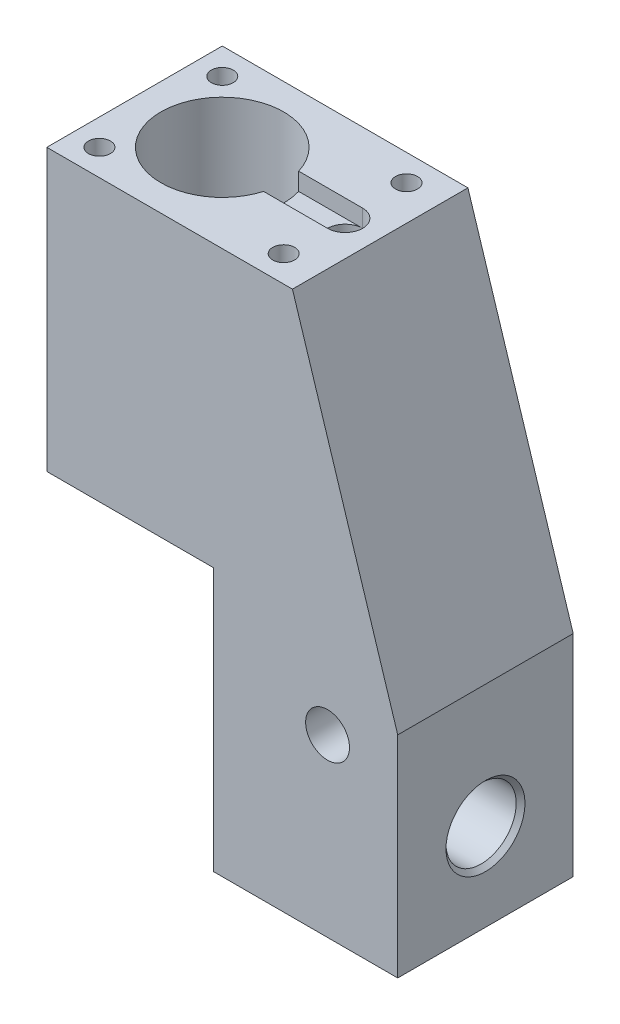
from build123d import *

# Parameters (mm, degrees)
SKETCH_1_W                = 28
SKETCH_1_H                = 20
SKETCH_2_W                = 40
SKETCH_2_H                = 20
SKETCH_3_W                = 40
SKETCH_3_H                = 20
EXTRUDE_1_DEPTH           = 24
SKETCH_4_W                = 19
SKETCH_4_H                = 20
CUT_EXTRUDE_1_DEPTH       = 30
HOLE_WIZARD_M31_D         = 2.5
HOLE_WIZARD_M31_DEPTH     = 9
HOLE_WIZARD_M31_TIP       = 0.751075774
SKETCH_11_R               = 7
CUT_EXTRUDE_3_DEPTH       = 32
SKETCH_12_R               = 2
CUT_EXTRUDE_4_DEPTH       = 30
SKETCH_13_R               = 1.25
CUT_EXTRUDE_5_DEPTH       = 22
CUT_EXTRUDE_6_REACH       = 42
SKETCH_14_R               = 1.6
SKETCH_15_R               = 4
CUT_EXTRUDE_7_DEPTH       = 21
CHAMFER_1_SIZE            = 0.5
HOLE_WIZARD_M41_D         = 3.3
HOLE_WIZARD_M41_DEPTH     = 10
HOLE_WIZARD_M41_TIP       = 0.991420021
SKETCH_21_R               = 2.5
CUT_EXTRUDE_8_DEPTH       = 20
CUT_EXTRUDE_9_REACH       = 64
SKETCH_22_R               = 1.25
SKETCH_23_W               = 12.954085538
SKETCH_23_H               = 2
CUT_EXTRUDE_10_DEPTH      = 2
CUT_EXTRUDE_10_DEPTH_BACK = 2


with BuildPart() as part:
    # Эскиз1 → По сечениям1 section 0
    with BuildSketch(Plane(origin=(0, 0, 0), x_dir=(1, 0, 0), z_dir=(0, 1, 0))):
        with Locations((14, 10)):
            Rectangle(SKETCH_1_W, SKETCH_1_H)
    # Эскиз2 → По сечениям1 section 1
    with BuildSketch(Plane(origin=(0, -38, 0), x_dir=(1, 0, 0), z_dir=(0, 1, 0))):
        with Locations((20, 10)):
            Rectangle(SKETCH_2_W, SKETCH_2_H)
    loft()

    # Эскиз3 → Бобышка-Вытянуть1 (add)
    with BuildSketch(Plane.XZ.offset(38)):
        with Locations((20, -10)):
            Rectangle(SKETCH_3_W, SKETCH_3_H)
    extrude(amount=EXTRUDE_1_DEPTH)

    # Эскиз4 → Вырез-Вытянуть1 (cut)
    with BuildSketch(Plane.XZ.offset(62)):
        with Locations((9.5, -10)):
            Rectangle(SKETCH_4_W, SKETCH_4_H)
    extrude(amount=-CUT_EXTRUDE_1_DEPTH, mode=Mode.SUBTRACT)

    # Отверстие обработанное метчиком M31
    with Locations(Plane(origin=(0, 0, 0), x_dir=(1, 0, 0), z_dir=(0, 1, 0))):
        with Locations((3, 3), (3, 17), (24, 17), (24, 3)):
            Hole(HOLE_WIZARD_M31_D / 2, depth=HOLE_WIZARD_M31_DEPTH)
            with Locations((0, 0, -(HOLE_WIZARD_M31_DEPTH + HOLE_WIZARD_M31_TIP / 2))):  # 118° drill point
                Cone(0, HOLE_WIZARD_M31_D / 2, HOLE_WIZARD_M31_TIP, mode=Mode.SUBTRACT)

    # Эскиз11 → Вырез-Вытянуть3 (cut)
    with BuildSketch(Plane(origin=(0, 0, 0), x_dir=(1, 0, 0), z_dir=(0, 1, 0))):
        with Locations((10, 10)):
            Circle(SKETCH_11_R)
    extrude(amount=-CUT_EXTRUDE_3_DEPTH, mode=Mode.SUBTRACT)

    # Эскиз12 → Вырез-Вытянуть4 (cut)
    with BuildSketch(Plane(origin=(0, 0, 0), x_dir=(1, 0, 0), z_dir=(0, 1, 0))):
        with Locations((24, 10)):
            Circle(SKETCH_12_R)
    extrude(amount=-CUT_EXTRUDE_4_DEPTH, mode=Mode.SUBTRACT)

    # Эскиз13 → Вырез-Вытянуть5 (cut)
    with BuildSketch(Plane(origin=(0, -30, 0), x_dir=(1, 0, 0), z_dir=(0, 1, 0))):
        with Locations((24, 10)):
            Circle(SKETCH_13_R)
    extrude(amount=-CUT_EXTRUDE_5_DEPTH, mode=Mode.SUBTRACT)

    # Эскиз14 → Вырез-Вытянуть6 (cut, up to next)
    with BuildSketch(Plane.ZY, mode=Mode.PRIVATE) as cut_extrude_6_sk1:
        with Locations((-13, -17)):
            Circle(SKETCH_14_R)
    cut_extrude_6_tool1 = extrude(cut_extrude_6_sk1.sketch, amount=-CUT_EXTRUDE_6_REACH, mode=Mode.PRIVATE) & part.part
    add(cut_extrude_6_tool1.solids().sort_by_distance((0, -17, -13))[0], mode=Mode.SUBTRACT)
    # Эскиз14 → Вырез-Вытянуть6 (cut, up to next)
    with BuildSketch(Plane.ZY, mode=Mode.PRIVATE) as cut_extrude_6_sk2:
        with Locations((-7, -17)):
            Circle(SKETCH_14_R)
    cut_extrude_6_tool2 = extrude(cut_extrude_6_sk2.sketch, amount=-CUT_EXTRUDE_6_REACH, mode=Mode.PRIVATE) & part.part
    add(cut_extrude_6_tool2.solids().sort_by_distance((0, -17, -7))[0], mode=Mode.SUBTRACT)

    # Эскиз15 → Вырез-Вытянуть7 (cut)
    with BuildSketch(Plane(origin=(40, 0, 0), x_dir=(0, 0, -1), z_dir=(1, 0, 0))):
        with Locations((10, -52)):
            Circle(SKETCH_15_R)
    extrude(amount=-CUT_EXTRUDE_7_DEPTH, mode=Mode.SUBTRACT)

    # Фаска1
    chamfer_1_edges = [part.edges().sort_by_distance(p)[0] for p in [
        (40, -52, -6),
    ]]
    chamfer(chamfer_1_edges, length=CHAMFER_1_SIZE)

    # Отверстие обработанное метчиком M41
    with Locations(Plane(origin=(0, -62, 0), x_dir=(-1, 0, 0), z_dir=(0, -1, 0))):
        with Locations((-32, 10), (-24, 10)):
            Hole(HOLE_WIZARD_M41_D / 2, depth=HOLE_WIZARD_M41_DEPTH)
            with Locations((0, 0, -(HOLE_WIZARD_M41_DEPTH + HOLE_WIZARD_M41_TIP / 2))):  # 118° drill point
                Cone(0, HOLE_WIZARD_M41_D / 2, HOLE_WIZARD_M41_TIP, mode=Mode.SUBTRACT)

    # Эскиз21 → Вырез-Вытянуть8 (cut)
    with BuildSketch(Plane.XY):
        with Locations((32, -42)):
            Circle(SKETCH_21_R)
    extrude(amount=-CUT_EXTRUDE_8_DEPTH, mode=Mode.SUBTRACT)

    # Эскиз22 → Вырез-Вытянуть9 (cut, up to next)
    with BuildSketch(Plane.XZ.offset(62), mode=Mode.PRIVATE) as cut_extrude_9_sk1:
        with Locations((32, -10)):
            Circle(SKETCH_22_R)
    cut_extrude_9_tool1 = extrude(cut_extrude_9_sk1.sketch, amount=-CUT_EXTRUDE_9_REACH, mode=Mode.PRIVATE) & part.part
    add(cut_extrude_9_tool1.solids().sort_by_distance((32, -62, -10))[0], mode=Mode.SUBTRACT)

    # Эскиз23 → Вырез-Вытянуть10 (cut, two sides)
    with BuildSketch(Plane.XY.offset(-10)) as cut_extrude_10_sk:
        with Locations((17.522957231, -1)):
            Rectangle(SKETCH_23_W, SKETCH_23_H)
    extrude(amount=CUT_EXTRUDE_10_DEPTH, mode=Mode.SUBTRACT)
    extrude(cut_extrude_10_sk.sketch, amount=-CUT_EXTRUDE_10_DEPTH_BACK, mode=Mode.SUBTRACT)


solid = part.part
